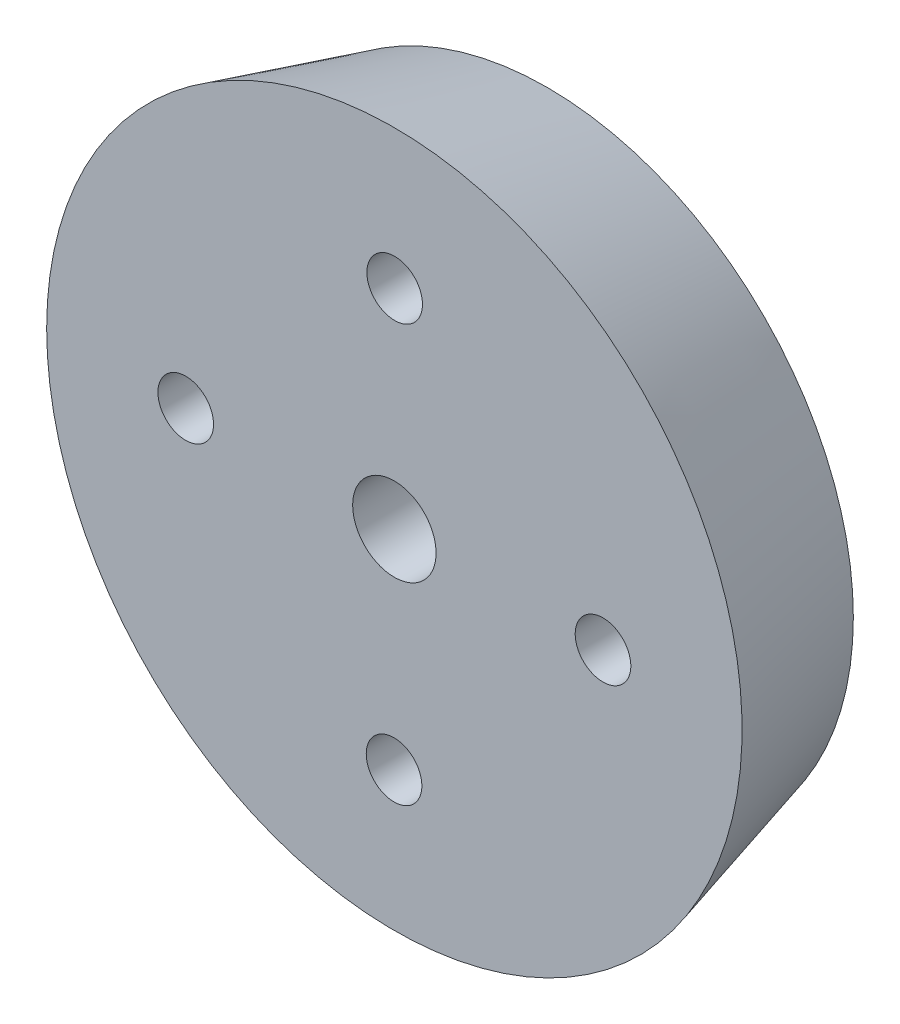
from build123d import *

# Parameters (mm, degrees)
F_4_0_4_DIAMETER_HOLE1_D     = 4
F_4_0_4_DIAMETER_HOLE1_DEPTH = 11
SKETCH4_R                    = 3
CUT_EXTRUDE1_DEPTH           = 12


with BuildPart() as part:
    # Sketch1 → Revolve1 (revolve)
    with BuildSketch(Plane.XZ):
        Polygon((25, -94), (0, -94), (0, -105), (22, -105), align=None)
    revolve(axis=Axis((0, 0, -94), (0, 0, -1)))

    # Ø4.0 (4) Diameter Hole1
    with Locations(Plane(origin=(0, 0, -105), x_dir=(-1, 0, 0), z_dir=(0, 0, -1))):
        with Locations((-14.999982566, -0.022869707), (0.022869707, -14.999982566), (-0.022869707, 14.999982566), (14.999982566, 0.022869707)):
            Hole(F_4_0_4_DIAMETER_HOLE1_D / 2, depth=F_4_0_4_DIAMETER_HOLE1_DEPTH)

    # Sketch4 → Cut-Extrude1 (cut, through all)
    with BuildSketch(Plane(origin=(0, 0, -105), x_dir=(-1, 0, 0), z_dir=(0, 0, -1))):
        Circle(SKETCH4_R)
    extrude(amount=-CUT_EXTRUDE1_DEPTH, mode=Mode.SUBTRACT)


solid = part.part
